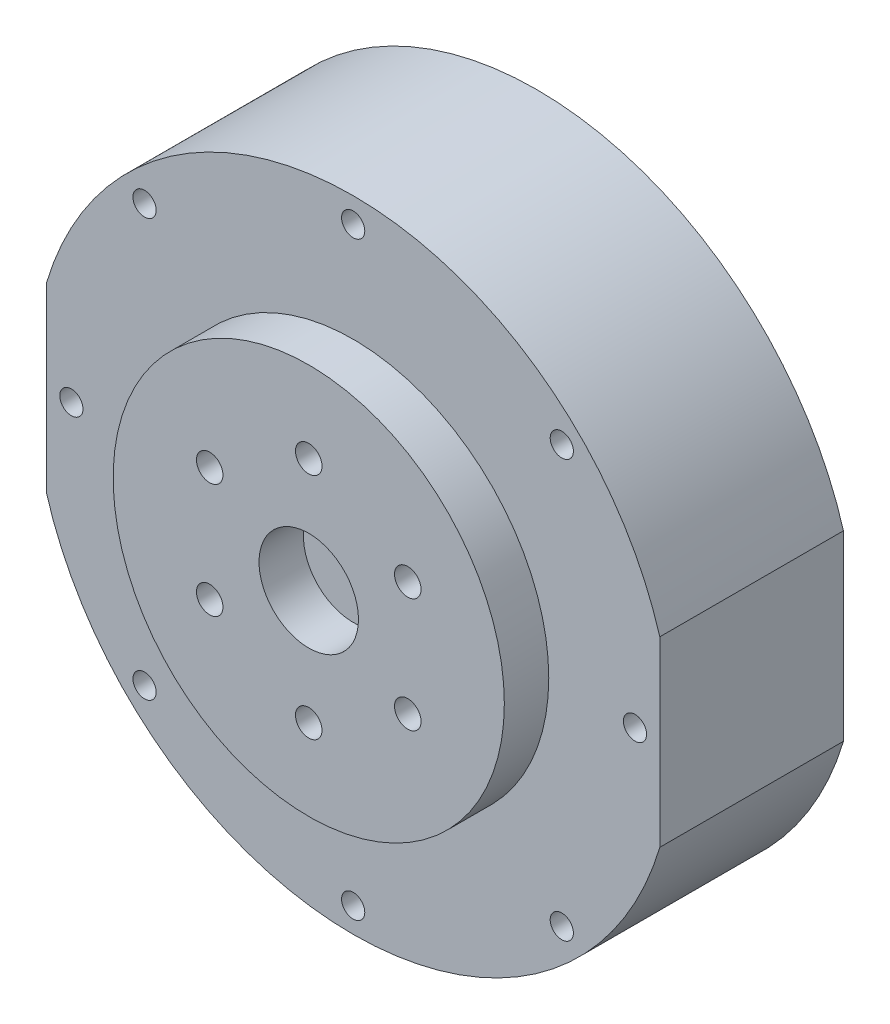
from build123d import *

# Parameters (mm, degrees)
SKETCH_1_R          = 48.25
EXTRUDE_1_DEPTH     = 27.7
SKETCH_2_R          = 29
EXTRUDE_2_DEPTH     = 8
SKETCH_3_R          = 29.5
SKETCH_3_R_2        = 2
SKETCH_3_R_3        = 7.5
EXTRUDE_3_DEPTH     = 6.7
SKETCH_4_R          = 1.75
CUT_EXTRUDE_1_DEPTH = 5
SKETCH_5_R          = 1.75
CUT_EXTRUDE_2_DEPTH = 5
CUT_EXTRUDE_3_DEPTH = 36.7


with BuildPart() as part:
    # 草图1 → 凸台-拉伸1 (new body)
    with BuildSketch(Plane.XY):
        Circle(SKETCH_1_R)
    extrude(amount=EXTRUDE_1_DEPTH)

    # 草图2 → 凸台-拉伸2 (add)
    with BuildSketch(Plane(origin=(0, 0, 0), x_dir=(-1, 0, 0), z_dir=(0, 0, -1))):
        Circle(SKETCH_2_R)
    extrude(amount=EXTRUDE_2_DEPTH)

    # 草图3 → 凸台-拉伸3 (add)
    with BuildSketch(Plane.XY.offset(27.7)):
        Circle(SKETCH_3_R)
        with Locations((0, 17.25)):
            Circle(SKETCH_3_R_2, mode=Mode.SUBTRACT)
        with Locations((14.938938215, 8.625)):
            Circle(SKETCH_3_R_2, mode=Mode.SUBTRACT)
        with Locations((14.938938215, -8.625)):
            Circle(SKETCH_3_R_2, mode=Mode.SUBTRACT)
        with Locations((0, -17.25)):
            Circle(SKETCH_3_R_2, mode=Mode.SUBTRACT)
        with Locations((-14.938938215, -8.625)):
            Circle(SKETCH_3_R_2, mode=Mode.SUBTRACT)
        with Locations((-14.938938215, 8.625)):
            Circle(SKETCH_3_R_2, mode=Mode.SUBTRACT)
        Circle(SKETCH_3_R_3, mode=Mode.SUBTRACT)
    extrude(amount=EXTRUDE_3_DEPTH)

    # 草图4 → 切除-拉伸1 (cut)
    with BuildSketch(Plane.XY.offset(27.7)):
        with Locations((0, 44.5)):
            Circle(SKETCH_4_R)
        with Locations((31.466251763, 31.466251763)):
            Circle(SKETCH_4_R)
        with Locations((31.466251763, -31.466251763)):
            Circle(SKETCH_4_R)
        with Locations((0, -44.5)):
            Circle(SKETCH_4_R)
        with Locations((-31.466251763, -31.466251763)):
            Circle(SKETCH_4_R)
        with Locations((-31.466251763, 31.466251763)):
            Circle(SKETCH_4_R)
        with Locations((-42.5, 0)):
            Circle(SKETCH_4_R)
        with Locations((42.5, 0)):
            Circle(SKETCH_4_R)
    extrude(amount=-CUT_EXTRUDE_1_DEPTH, mode=Mode.SUBTRACT)

    # 草图5 → 切除-拉伸2 (cut)
    with BuildSketch(Plane(origin=(0, 0, 0), x_dir=(-1, 0, 0), z_dir=(0, 0, -1))):
        with Locations((0, 42.5)):
            Circle(SKETCH_5_R)
        with Locations((30.0520382, 30.0520382)):
            Circle(SKETCH_5_R)
        with Locations((42.5, 0)):
            Circle(SKETCH_5_R)
        with Locations((30.0520382, -30.0520382)):
            Circle(SKETCH_5_R)
        with Locations((0, -42.5)):
            Circle(SKETCH_5_R)
        with Locations((-30.0520382, -30.0520382)):
            Circle(SKETCH_5_R)
        with Locations((-42.5, 0)):
            Circle(SKETCH_5_R)
        with Locations((-30.0520382, 30.0520382)):
            Circle(SKETCH_5_R)
    extrude(amount=-CUT_EXTRUDE_2_DEPTH, mode=Mode.SUBTRACT)

    # 草图6 → 切除-拉伸3 (cut, through all)
    with BuildSketch(Plane.XY.offset(27.7)):
        with BuildLine():
            Line((-46.25, 13.747727085), (-46.25, -13.747727085))
            ThreePointArc((-46.25, -13.747727085), (-48.25, 0), (-46.25, 13.747727085))
        make_face()
        with BuildLine():
            Line((46.25, -13.747727085), (46.25, 13.747727085))
            ThreePointArc((46.25, 13.747727085), (48.25, 0), (46.25, -13.747727085))
        make_face()
    extrude(amount=-CUT_EXTRUDE_3_DEPTH, mode=Mode.SUBTRACT)


solid = part.part
